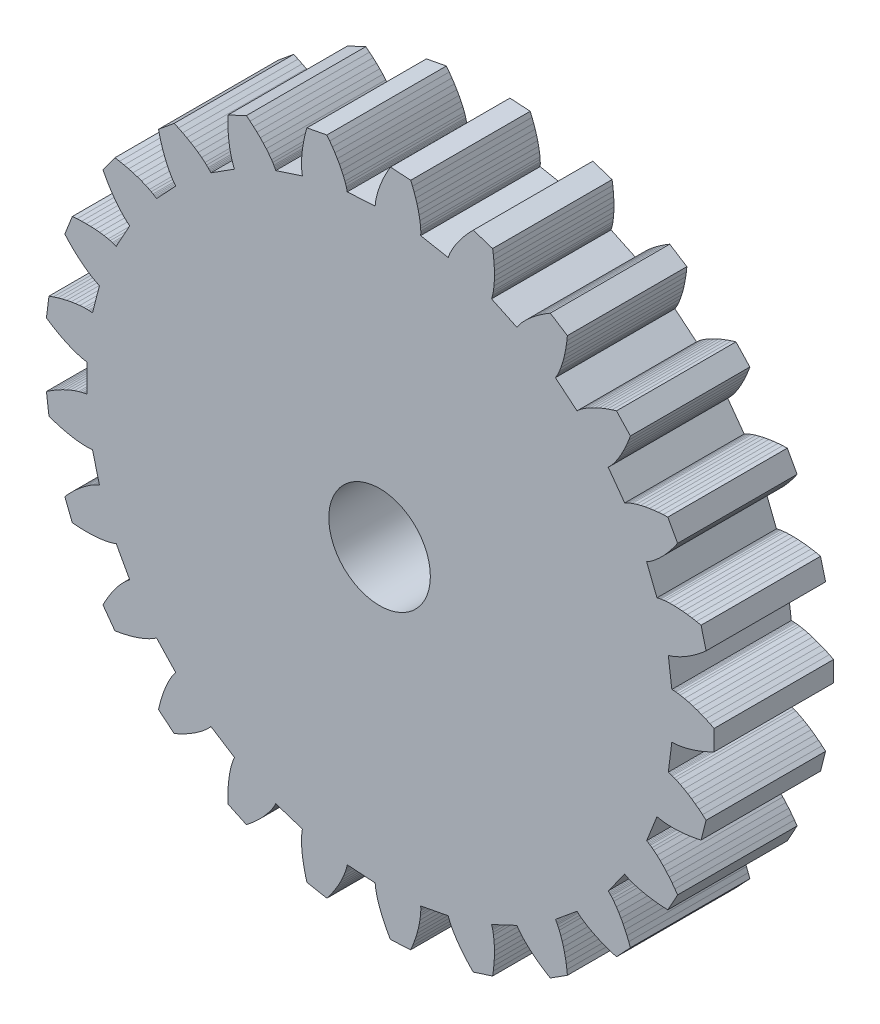
from build123d import *

# Parameters (mm, degrees)
MODEL_R             = 1.7
BOSS_EXTRUDE1_DEPTH = 4


with BuildPart() as part:
    # Model → Boss-Extrude1 (new body)
    with BuildSketch(Plane.XY):
        Polygon((22.5153116, 13.49371), (22.5501244, 13.4944492), (22.5850516, 13.4935692), (22.6200756, 13.4916244), (22.6551524, 13.4887996), (22.7254732, 13.4809588), (22.7959612, 13.4705748), (22.9373156, 13.4433212), (23.0790396, 13.4084996), (23.2209836, 13.3669196), (23.3630332, 13.319118), (23.5050916, 13.2654556), (23.6470444, 13.2062052), (23.7888124, 13.1415956), (23.93029, 13.071794), (23.93029, 12.391466), (23.7888124, 12.3216644), (23.6470444, 12.257046), (23.5050916, 12.1978044), (23.3630332, 12.144142), (23.2209836, 12.0963316), (23.0790396, 12.0547516), (22.9373156, 12.01993), (22.7959612, 11.9926764), (22.7254732, 11.9822924), (22.6551524, 11.9744516), (22.6200756, 11.9716356), (22.5850516, 11.969682), (22.5501244, 11.9688108), (22.5153116, 11.96955), (22.397462, 11.036662), (22.4313596, 11.0287244), (22.4649756, 11.0191852), (22.4984068, 11.00859), (22.5316884, 10.9971324), (22.5978468, 10.9720524), (22.6635388, 10.9444644), (22.7936732, 10.8829084), (22.9222852, 10.8139428), (23.0494276, 10.7383684), (23.1751356, 10.6567396), (23.299374, 10.569426), (23.4221428, 10.4767444), (23.5433804, 10.378906), (23.6630604, 10.2761132), (23.4938716, 9.6171516), (23.3394756, 9.5847324), (23.1860916, 9.5574084), (23.0338604, 9.5353204), (22.8829228, 9.5186708), (22.733446, 9.5076972), (22.5856236, 9.5027252), (22.4396932, 9.5042388), (22.295998, 9.5129948), (22.2251404, 9.5204748), (22.1550836, 9.5303572), (22.1204028, 9.53635), (22.0860036, 9.5431788), (22.0519476, 9.5510108), (22.0184196, 9.5603828), (21.6722716, 8.6861204), (21.7031332, 8.6699988), (21.7333172, 8.6523988), (21.76307, 8.633822), (21.7924532, 8.6144532), (21.8502868, 8.5737004), (21.9070556, 8.530642), (22.0178036, 8.4386644), (22.1252164, 8.3398756), (22.2295756, 8.2350588), (22.331022, 8.1247332), (22.4296524, 8.0092684), (22.5255108, 7.8889636), (22.6186148, 7.7640476), (22.7089732, 7.634714), (22.3812172, 7.0385404), (22.2236092, 7.0455364), (22.068254, 7.0572052), (21.91531, 7.0736788), (21.7649708, 7.0950892), (21.6174652, 7.12163), (21.4730484, 7.153574), (21.3320812, 7.1913348), (21.195074, 7.2355548), (21.1283084, 7.2604148), (21.0629068, 7.2874132), (21.0308044, 7.3018452), (20.999186, 7.3170076), (20.9681484, 7.3330676), (20.9379996, 7.3504828), (20.3853068, 6.5897668), (20.4111876, 6.566482), (20.4360564, 6.5419212), (20.4602476, 6.5165332), (20.4838844, 6.4904676), (20.5297764, 6.4366116), (20.5740492, 6.3807932), (20.6584412, 6.264158), (20.737914, 6.1417588), (20.8129252, 6.014282), (20.8837564, 5.882194), (20.950566, 5.7458292), (21.0134948, 5.6054604), (21.0726132, 5.4613164), (21.1279652, 5.313582), (20.6622428, 4.8176404), (20.5113228, 4.8636116), (20.3637556, 4.9135604), (20.2197172, 4.9675484), (20.0794276, 5.0256724), (19.9431508, 5.0880556), (19.8112124, 5.154918), (19.6840612, 5.22655), (19.562366, 5.3034532), (19.5038724, 5.3441356), (19.4472444, 5.3865516), (19.4197444, 5.4085076), (19.392878, 5.431062), (19.3668124, 5.454338), (19.3419436, 5.4787052), (18.6174308, 4.8793372), (18.6367116, 4.8503412), (18.65469, 4.8203684), (18.671806, 4.789762), (18.6882268, 4.7586364), (18.7192732, 4.6950564), (18.748278, 4.6299804), (18.8010076, 4.4960268), (18.8475508, 4.3577084), (18.888506, 4.2155796), (18.9242516, 4.0700276), (18.9550604, 3.921334), (18.9810996, 3.7697276), (19.00251, 3.6154108), (19.0193796, 3.4585508), (18.4449596, 3.0940108), (18.310214, 3.1760708), (18.1797012, 3.2611404), (18.0536148, 3.3492548), (17.9321836, 3.4404404), (17.8157068, 3.5347676), (17.7045452, 3.6323332), (17.5992092, 3.7333396), (17.5004468, 3.838086), (17.4539124, 3.8920388), (17.4096132, 3.947206), (17.3884316, 3.9753132), (17.3680332, 4.003834), (17.3485676, 4.0328564), (17.3305364, 4.0626444), (16.4797348, 3.6622884), (16.4911924, 3.6294116), (16.501154, 3.59591), (16.5101212, 3.5620124), (16.5182788, 3.5277716), (16.5325524, 3.4584716), (16.5444588, 3.38823), (16.5622172, 3.2453708), (16.5729004, 3.0998188), (16.5772212, 2.9519788), (16.575646, 2.802106), (16.5685092, 2.6504204), (16.5560308, 2.497098), (16.5383868, 2.342306), (16.515718, 2.1861764), (15.8686892, 1.9759444), (15.7585836, 2.0889364), (15.6533268, 2.203794), (15.5531124, 2.3204996), (15.458178, 2.439018), (15.368814, 2.5593404), (15.2854076, 2.6814932), (15.2084956, 2.8055204), (15.1388964, 2.9315364), (15.107234, 2.9953628), (15.0780444, 3.059814), (15.0645276, 3.0923036), (15.0518556, 3.1250044), (15.040222, 3.1579604), (15.0301724, 3.1912948), (14.1065244, 3.0151012), (14.1094548, 2.9804116), (14.110766, 2.9454844), (14.1110212, 2.9104164), (14.110414, 2.8752252), (14.1069996, 2.8045612), (14.1010596, 2.733554), (14.082738, 2.5907652), (14.0568836, 2.4471404), (14.024306, 2.3028644), (13.9855068, 2.1580868), (13.9408732, 2.0129484), (13.8906516, 1.867546), (13.8350708, 1.7220028), (13.7742892, 1.5764156), (13.0953076, 1.5337004), (13.0167588, 1.6705228), (12.9433668, 1.8079524), (12.8753252, 1.94591), (12.8128452, 2.0843076), (12.7562172, 2.2230836), (12.7058108, 2.3621324), (12.662154, 2.5013924), (12.6260828, 2.640758), (12.61129, 2.710454), (12.5990492, 2.7801412), (12.5940332, 2.8149716), (12.5898884, 2.849802), (12.5868172, 2.8846148), (12.585374, 2.9194012), (11.6469332, 2.9784404), (11.641134, 2.9441116), (11.6337244, 2.9099588), (11.62525, 2.8759292), (11.6159044, 2.8419964), (11.5950308, 2.7743948), (11.5716228, 2.7071012), (11.5183564, 2.57335), (11.4576012, 2.4406636), (11.390158, 2.3090244), (11.3165812, 2.17845), (11.2372492, 2.0489668), (11.1524524, 1.9206276), (11.0624196, 1.7934764), (10.9673444, 1.6675836), (10.2990636, 1.7950604), (10.2570084, 1.9471156), (10.22011, 2.0984756), (10.188518, 2.249026), (10.1624172, 2.3986172), (10.1420716, 2.5471084), (10.1278332, 2.6943324), (10.120186, 2.8400692), (10.1199044, 2.9840284), (10.122914, 3.0552116), (10.1283788, 3.1257524), (10.1321804, 3.1607412), (10.1368356, 3.1955012), (10.1425204, 3.2299884), (10.1497628, 3.2640444), (9.2554892, 3.5546116), (9.2413388, 3.5227996), (9.225666, 3.4915596), (9.2089988, 3.4607068), (9.1915132, 3.430162), (9.154474, 3.369882), (9.1150676, 3.3105172), (9.030218, 3.1942252), (8.9383724, 3.0808108), (8.840314, 2.9700804), (8.7365708, 2.861902), (8.62753, 2.756214), (8.513482, 2.6529988), (8.3946556, 2.55223), (8.2712532, 2.453934), (7.6556756, 2.7436036), (7.6527628, 2.9013436), (7.6546548, 3.05713), (7.6614924, 3.2108044), (7.6734164, 3.362182), (7.6906468, 3.5110692), (7.7134652, 3.6572108), (7.742294, 3.8002724), (7.7778196, 3.9397788), (7.798438, 4.0079788), (7.8212828, 4.0749468), (7.8336732, 4.1078852), (7.8468204, 4.1404012), (7.8608916, 4.1723804), (7.8763884, 4.2035676), (7.08247, 4.7074028), (7.0608484, 4.6801052), (7.0379068, 4.6537492), (7.0140852, 4.6280092), (6.9895508, 4.6027796), (6.938678, 4.5535964), (6.8857548, 4.5059004), (6.774646, 4.4143628), (6.6574828, 4.3273572), (6.5349692, 4.2444876), (6.4075804, 4.1655076), (6.275686, 4.0902588), (6.13955, 4.0186444), (5.9994012, 3.9506028), (5.8554332, 3.8860812), (5.331226, 4.3197364), (5.3676316, 4.4732436), (5.4082084, 4.623662), (5.4530444, 4.7708068), (5.5022452, 4.9144668), (5.5559604, 5.0543956), (5.6144012, 5.1902676), (5.6779108, 5.3216604), (5.7470084, 5.4479492), (5.783942, 5.5088804), (5.8227236, 5.5680604), (5.8429108, 5.5968892), (5.8637316, 5.6251108), (5.885318, 5.6525932), (5.9080836, 5.6789404), (5.2643988, 6.36439), (5.2366788, 6.3433316), (5.207894, 6.3235052), (5.1784228, 6.3044972), (5.1483884, 6.286158), (5.0868852, 6.2511692), (5.023754, 6.2181428), (4.8933732, 6.157106), (4.758258, 6.101974), (4.6189804, 6.0521748), (4.475954, 6.0073564), (4.3294868, 5.9672724), (4.1798164, 5.9317644), (4.027154, 5.9007092), (3.871658, 5.8740188), (3.4717684, 6.4244148), (3.5452044, 6.5640532), (3.6219228, 6.6996436), (3.7019412, 6.8310188), (3.7853212, 6.9579324), (3.872142, 7.0801028), (3.9625444, 7.197178), (4.0567308, 7.3086476), (4.1550708, 7.4137812), (4.2059964, 7.4636156), (4.2582684, 7.511294), (4.284994, 7.5341916), (4.3121772, 7.55635), (4.3399236, 7.577602), (4.3685236, 7.5974636), (3.9155348, 8.4214516), (3.8834412, 8.4079436), (3.8506348, 8.3959052), (3.817362, 8.384826), (3.783702, 8.37453), (3.7154316, 8.3559356), (3.6460788, 8.3396468), (3.50461, 8.3129476), (3.360026, 8.2931564), (3.2127404, 8.2795516), (3.0630612, 8.2717108), (2.9112348, 8.2693172), (2.7574372, 8.272142), (2.6018356, 8.2800268), (2.4445972, 8.2928484), (2.1941492, 8.9254012), (2.2999956, 9.0423884), (2.4080244, 9.15465), (2.5182004, 9.2619924), (2.6305236, 9.364178), (2.7450028, 9.4609252), (2.8616732, 9.5518292), (2.9806316, 9.6363796), (3.1020276, 9.713758), (3.163742, 9.7493628), (3.2262308, 9.7825388), (3.257814, 9.7980708), (3.2896524, 9.8127756), (3.3218076, 9.8264508), (3.3544468, 9.8385772), (3.1206044, 10.7493332), (3.0861612, 10.744238), (3.0513924, 10.7407356), (3.0164124, 10.7382716), (2.9812564, 10.7366788), (2.9105044, 10.7356404), (2.8392772, 10.73711), (2.6956172, 10.7464292), (2.550646, 10.7632196), (2.40461, 10.7866804), (2.2576852, 10.8163012), (2.1100212, 10.8517388), (1.9617588, 10.8927292), (1.8130124, 10.9390612), (1.6638964, 10.9905764), (1.5786332, 11.6655452), (1.7102548, 11.7525332), (1.8428004, 11.8343996), (1.9762172, 11.9109684), (2.1104172, 11.9820196), (2.2453652, 12.0472452), (2.3809732, 12.1062932), (2.5172148, 12.1586004), (2.654046, 12.2033572), (2.7226772, 12.2224884), (2.791458, 12.2390852), (2.8259012, 12.2462748), (2.8603972, 12.252602), (2.894946, 12.2578468), (2.9295828, 12.2614812), (2.9295828, 13.2017788), (2.894946, 13.2054044), (2.8603972, 13.210658), (2.8259012, 13.2169764), (2.791458, 13.224166), (2.7226772, 13.2407628), (2.654046, 13.2599028), (2.5172148, 13.3046596), (2.3809732, 13.3569668), (2.2453652, 13.416006), (2.1104172, 13.4812404), (1.9762172, 13.5522828), (1.8428004, 13.6288604), (1.7102548, 13.7107268), (1.5786332, 13.797706), (1.6638964, 14.4726748), (1.8130124, 14.5241988), (1.9617588, 14.5705308), (2.1100212, 14.6115124), (2.2576852, 14.64695), (2.40461, 14.6765796), (2.550646, 14.7000404), (2.6956172, 14.716822), (2.8392772, 14.7261412), (2.9105044, 14.7276108), (2.9812564, 14.7265812), (3.0164124, 14.7249796), (3.0513924, 14.7225244), (3.0861612, 14.7190132), (3.1206044, 14.713918), (3.3544468, 15.624674), (3.3218076, 15.6368004), (3.2896524, 15.6504844), (3.257814, 15.6651804), (3.2262308, 15.6807124), (3.163742, 15.7138972), (3.1020276, 15.7494932), (2.9806316, 15.8268716), (2.8616732, 15.911422), (2.7450028, 16.0023348), (2.6305236, 16.0990732), (2.5182004, 16.2012676), (2.4080244, 16.30861), (2.2999956, 16.4208716), (2.1941492, 16.5378588), (2.4445972, 17.1704116), (2.6018356, 17.1832244), (2.7574372, 17.1911092), (2.9112348, 17.1939428), (3.0630612, 17.1915404), (3.2127404, 17.1836996), (3.360026, 17.1701036), (3.50461, 17.1503124), (3.6460788, 17.1236132), (3.7154316, 17.1073156), (3.783702, 17.0887212), (3.817362, 17.078434), (3.8506348, 17.0673548), (3.8834412, 17.0553076), (3.9155348, 17.0418084), (4.3685236, 17.8657964), (4.3399236, 17.885658), (4.3121772, 17.9069012), (4.284994, 17.9290596), (4.2582684, 17.9519572), (4.2059964, 17.9996356), (4.1550708, 18.04947), (4.0567308, 18.1546036), (3.9625444, 18.266082), (3.872142, 18.3831484), (3.7853212, 18.5053188), (3.7019412, 18.6322324), (3.6219228, 18.7636076), (3.5452044, 18.8992068), (3.4717684, 19.0388364), (3.871658, 19.5892412), (4.027154, 19.5625508), (4.1798164, 19.5314868), (4.3294868, 19.4959788), (4.475954, 19.4559036), (4.6189804, 19.4110764), (4.758258, 19.361286), (4.8933732, 19.306154), (5.023754, 19.2451172), (5.0868852, 19.212082), (5.1483884, 19.1770932), (5.1784228, 19.158754), (5.207894, 19.1397548), (5.2366788, 19.1199284), (5.2643988, 19.09887), (5.9080836, 19.7843108), (5.885318, 19.8106668), (5.8637316, 19.8381404), (5.8429108, 19.866362), (5.8227236, 19.8951908), (5.783942, 19.9543708), (5.7470084, 20.015302), (5.6779108, 20.1415908), (5.6144012, 20.2729836), (5.5559604, 20.4088644), (5.5022452, 20.5487844), (5.4530444, 20.6924532), (5.4082084, 20.839598), (5.3676316, 20.9900076), (5.331226, 21.1435236), (5.8554332, 21.5771788), (5.9994012, 21.5126572), (6.13955, 21.4446068), (6.275686, 21.3729924), (6.4075804, 21.2977436), (6.5349692, 21.2187636), (6.6574828, 21.135894), (6.774646, 21.0488972), (6.8857548, 20.9573508), (6.938678, 20.9096548), (6.9895508, 20.8604804), (7.0140852, 20.835242), (7.0379068, 20.809502), (7.0608484, 20.783146), (7.08247, 20.7558572), (7.8763884, 21.2596924), (7.8608916, 21.2908708), (7.8468204, 21.3228588), (7.8336732, 21.355366), (7.8212828, 21.3883132), (7.798438, 21.4552724), (7.7778196, 21.5234724), (7.742294, 21.6629876), (7.7134652, 21.8060404), (7.6906468, 21.952182), (7.6734164, 22.1010692), (7.6614924, 22.2524556), (7.6546548, 22.40613), (7.6527628, 22.5619076), (7.6556756, 22.7196476), (8.2712532, 23.0093172), (8.3946556, 22.9110212), (8.513482, 22.8102612), (8.62753, 22.7070372), (8.7365708, 22.6013492), (8.840314, 22.4931708), (8.9383724, 22.3824404), (9.030218, 22.2690348), (9.1150676, 22.152734), (9.154474, 22.093378), (9.1915132, 22.0330892), (9.2089988, 22.0025532), (9.225666, 21.9716916), (9.2413388, 21.9404604), (9.2554892, 21.9086484), (10.1497628, 22.1992156), (10.1425204, 22.2332716), (10.1368356, 22.26775), (10.1321804, 22.30251), (10.1283788, 22.3374988), (10.122914, 22.4080396), (10.1199044, 22.4792228), (10.120186, 22.623182), (10.1278332, 22.7689188), (10.1420716, 22.9161428), (10.1624172, 23.064634), (10.188518, 23.214234), (10.22011, 23.3647756), (10.2570084, 23.5161356), (10.2990636, 23.6681908), (10.9673444, 23.7956764), (11.0624196, 23.6697748), (11.1524524, 23.5426324), (11.2372492, 23.4142932), (11.3165812, 23.28481), (11.390158, 23.1542268), (11.4576012, 23.0225876), (11.5183564, 22.8899012), (11.5716228, 22.7561588), (11.5950308, 22.6888652), (11.6159044, 22.6212636), (11.62525, 22.5873308), (11.6337244, 22.5533012), (11.641134, 22.5191484), (11.6469332, 22.4848108), (12.585374, 22.5438588), (12.5868172, 22.5786452), (12.5898884, 22.613458), (12.5940332, 22.6482796), (12.5990492, 22.68311), (12.61129, 22.7527972), (12.6260828, 22.8224932), (12.662154, 22.9618676), (12.7058108, 23.1011188), (12.7562172, 23.2401764), (12.8128452, 23.3789436), (12.8753252, 23.51735), (12.9433668, 23.6553076), (13.0167588, 23.7927372), (13.0953076, 23.9295596), (13.7742892, 23.8868356), (13.8350708, 23.7412484), (13.8906516, 23.5957052), (13.9408732, 23.4503116), (13.9855068, 23.3051644), (14.024306, 23.1603956), (14.0568836, 23.0161196), (14.082738, 22.872486), (14.1010596, 22.7296972), (14.1069996, 22.6586988), (14.110414, 22.588026), (14.1110212, 22.5528348), (14.110766, 22.5177668), (14.1094548, 22.4828484), (14.1065244, 22.44815), (15.0301724, 22.2719564), (15.040222, 22.3052908), (15.0518556, 22.3382468), (15.0645276, 22.3709476), (15.0780444, 22.4034372), (15.107234, 22.4678884), (15.1388964, 22.5317236), (15.2084956, 22.6577396), (15.2854076, 22.7817668), (15.368814, 22.9039108), (15.458178, 23.024242), (15.5531124, 23.1427604), (15.6533268, 23.2594572), (15.7585836, 23.3743236), (15.8686892, 23.4873068), (16.515718, 23.2770748), (16.5383868, 23.1209452), (16.5560308, 22.9661532), (16.5685092, 22.8128396), (16.575646, 22.661154), (16.5772212, 22.5112812), (16.5729004, 22.3634324), (16.5622172, 22.2178892), (16.5444588, 22.07503), (16.5325524, 22.0047796), (16.5182788, 21.9354796), (16.5101212, 21.9012476), (16.501154, 21.8673412), (16.4911924, 21.8338484), (16.4797348, 21.8009628), (17.3305364, 21.4006068), (17.3485676, 21.4303948), (17.3680332, 21.4594172), (17.3884316, 21.4879468), (17.4096132, 21.516054), (17.4539124, 21.5712212), (17.5004468, 21.625174), (17.5992092, 21.7299204), (17.7045452, 21.830918), (17.8157068, 21.9284924), (17.9321836, 22.0228108), (18.0536148, 22.1139964), (18.1797012, 22.2021108), (18.310214, 22.2871892), (18.4449596, 22.3692404), (19.0193796, 22.0047092), (19.00251, 21.8478404), (18.9810996, 21.6935236), (18.9550604, 21.541926), (18.9242516, 21.3932324), (18.888506, 21.2476716), (18.8475508, 21.1055428), (18.8010076, 20.9672332), (18.748278, 20.8332708), (18.7192732, 20.7681948), (18.6882268, 20.7046236), (18.671806, 20.6734892), (18.65469, 20.6428828), (18.6367116, 20.6129188), (18.6174308, 20.5839228), (19.3419436, 19.9845548), (19.3668124, 20.008922), (19.392878, 20.032198), (19.4197444, 20.0547436), (19.4472444, 20.0767084), (19.5038724, 20.1191244), (19.562366, 20.1598068), (19.6840612, 20.2367012), (19.8112124, 20.3083332), (19.9431508, 20.3751956), (20.0794276, 20.4375876), (20.2197172, 20.4957116), (20.3637556, 20.5496996), (20.5113228, 20.5996396), (20.6622428, 20.6456108), (21.1279652, 20.1496692), (21.0726132, 20.0019348), (21.0134948, 19.8577908), (20.950566, 19.7174308), (20.8837564, 19.581066), (20.8129252, 19.448978), (20.737914, 19.3215012), (20.6584412, 19.199102), (20.5740492, 19.0824668), (20.5297764, 19.0266484), (20.4838844, 18.9727924), (20.4602476, 18.946718), (20.4360564, 18.92133), (20.4111876, 18.896778), (20.3853068, 18.8734844), (20.9379996, 18.1127684), (20.9681484, 18.1301836), (20.999186, 18.1462436), (21.0308044, 18.161406), (21.0629068, 18.175838), (21.1283084, 18.2028452), (21.195074, 18.2277052), (21.3320812, 18.2719164), (21.4730484, 18.3096772), (21.6174652, 18.34163), (21.7649708, 18.3681708), (21.91531, 18.3895724), (22.068254, 18.406046), (22.2236092, 18.4177236), (22.3812172, 18.4247108), (22.7089732, 17.8285372), (22.6186148, 17.6992124), (22.5255108, 17.5742964), (22.4296524, 17.4539916), (22.331022, 17.3385268), (22.2295756, 17.2282012), (22.1252164, 17.1233844), (22.0178036, 17.0245956), (21.9070556, 16.9326092), (21.8502868, 16.8895508), (21.7924532, 16.8488068), (21.76307, 16.8294292), (21.7333172, 16.8108612), (21.7031332, 16.7932612), (21.6722716, 16.7771308), (22.0184196, 15.9028684), (22.0519476, 15.9122404), (22.0860036, 15.9200812), (22.1204028, 15.9269012), (22.1550836, 15.932894), (22.2251404, 15.9427852), (22.295998, 15.9502564), (22.4396932, 15.9590124), (22.5856236, 15.9605348), (22.733446, 15.9555628), (22.8829228, 15.9445804), (23.0338604, 15.9279308), (23.1860916, 15.9058516), (23.3394756, 15.8785276), (23.4938716, 15.8460996), (23.6630604, 15.1871468), (23.5433804, 15.084354), (23.4221428, 14.9865156), (23.299374, 14.8938252), (23.1751356, 14.8065204), (23.0494276, 14.7248828), (22.9222852, 14.6493172), (22.7936732, 14.5803428), (22.6635388, 14.5187868), (22.5978468, 14.4912076), (22.5316884, 14.4661188), (22.4984068, 14.4546612), (22.4649756, 14.4440748), (22.4313596, 14.4345356), (22.397462, 14.4265892), align=None)
        with Locations((12.73163, 12.73163)):
            Circle(MODEL_R, mode=Mode.SUBTRACT)
    extrude(amount=BOSS_EXTRUDE1_DEPTH)


solid = part.part
